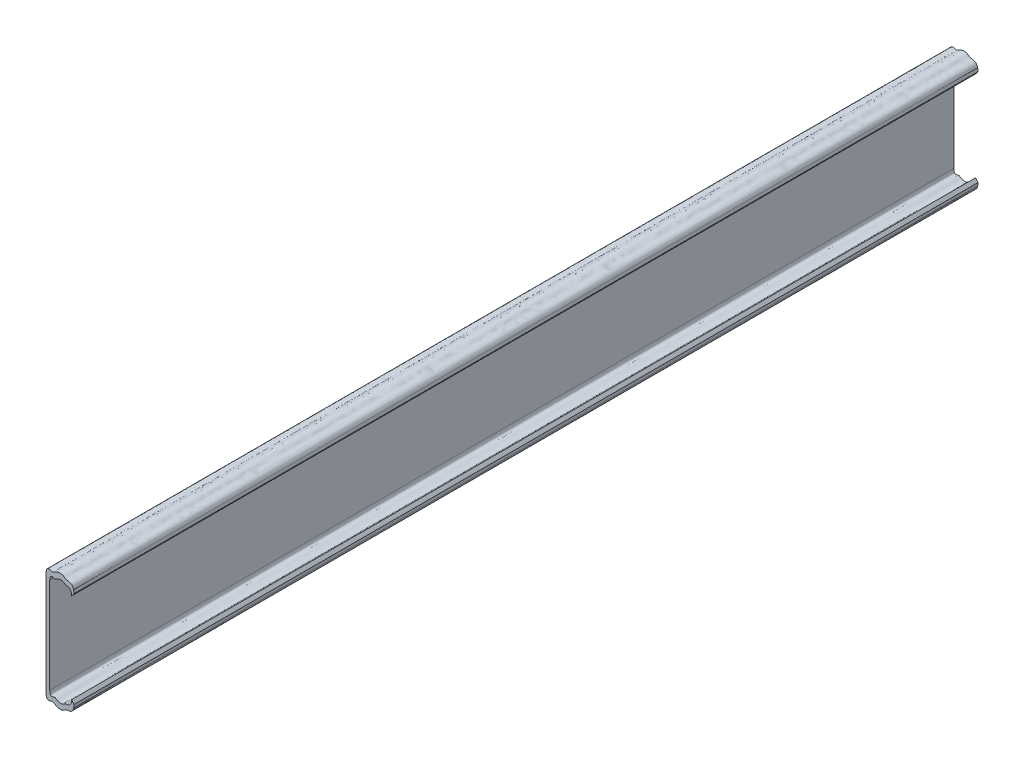
from build123d import *

# Parameters (mm, degrees)
BOSS_EXTRUDE1_DEPTH = 346


with BuildPart() as part:
    # Sketch1 → Boss-Extrude1 (new body)
    with BuildSketch(Plane.XY):
        with BuildLine():
            Line((1.430343878, 3918.17038545), (1.430343878, 3954.72901347))
            add(Edge.make_bspline(
                [(1.430343878, 3954.72901347), (1.492253744, 3955.777464486), (1.670742659, 3956.085303627), (1.952805311, 3956.243416154), (2.012188058, 3956.264605221), (2.256909987, 3956.328603169), (2.456399266, 3956.320672543), (2.757904339, 3956.259414864), (2.867475976, 3956.220539863), (3.0655829, 3956.142220977), (3.15726891, 3956.104553053), (3.353002763, 3956.075071328), (3.457565078, 3956.084802914), (3.826962952, 3956.236641407), (4.13936718, 3956.476934102), (4.679753676, 3956.732446606), (4.872375311, 3956.798700444), (5.259455237, 3956.891269903), (5.453877125, 3956.917683792), (5.821112383, 3956.92926878), (5.99223886, 3956.913589758), (6.380809615, 3956.829519875), (6.580504113, 3956.739636733), (6.800820646, 3956.589650728), (6.85125983, 3956.549497345), (7.057614936, 3956.384917414), (7.224473982, 3956.252870293), (7.694127073, 3956.129320115), (7.833489732, 3956.104363469), (7.996653054, 3956.081861553)],
                knots=[0, 0, 0, 0, 0.125, 0.125, 0.15625, 0.15625, 0.25, 0.25, 0.3125, 0.3125, 0.375, 0.375, 0.4375, 0.4375, 0.5625, 0.5625, 0.625, 0.625, 0.6875, 0.6875, 0.75, 0.75, 0.84375, 0.84375, 0.875, 0.875, 0.96875, 0.96875, 1, 1, 1, 1], degree=3))
            add(Edge.make_bspline(
                [(7.996653054, 3956.081861553), (8.088130688, 3956.069320908), (8.272759414, 3956.044010205), (8.548043297, 3955.98416982), (8.80734904, 3955.887619995), (9.114434379, 3955.705965873), (9.393499143, 3955.395178677), (9.581191859, 3954.993856883), (9.667993716, 3954.674443569), (9.713013038, 3954.432056806), (9.743778183, 3954.209962946), (9.766008001, 3953.938475631), (9.770007737, 3953.751998289), (9.772158651, 3953.651717495)],
                knots=[0, 0, 0, 0, 0.060950833, 0.123016678, 0.186644705, 0.247150337, 0.371687479, 0.497525343, 0.623449375, 0.683912366, 0.749156722, 0.865105526, 1, 1, 1, 1], degree=3))
            add(Edge.make_bspline(
                [(9.772158651, 3953.651717495), (9.902408791, 3953.815701891), (10.041613322, 3953.99095983), (10.350614598, 3954.379991179), (10.515877695, 3954.588056746), (10.692633126, 3954.810591115)],
                knots=[0, 0, 0, 0, 0.5, 0.5, 1, 1, 1, 1], degree=3))
            add(Edge.make_bspline(
                [(10.692633126, 3954.810591115), (10.691913281, 3954.862178833), (10.690503499, 3954.963210999), (10.684715317, 3955.117285928), (10.676302075, 3955.267777636), (10.659709804, 3955.478316933), (10.62998225, 3955.746722565), (10.584575759, 3955.973569096), (10.562899516, 3956.081861553)],
                knots=[0, 0, 0, 0, 0.133575651, 0.261601747, 0.383626033, 0.499198607, 0.760926415, 1, 1, 1, 1], degree=3))
            add(Edge.make_bspline(
                [(10.562899516, 3956.081861553), (10.216850212, 3957.618133962), (9.250723887, 3957.808490842), (8.406599882, 3957.92725494), (8.292912495, 3957.941948908), (7.466350409, 3958.083027006), (7.217801541, 3958.312264006), (6.889348881, 3958.571511488), (6.81435089, 3958.626610793), (6.402376678, 3958.879219503), (5.974893614, 3959.011194859), (5.200662558, 3959.003043812), (4.92380844, 3958.96768319), (4.373451983, 3958.834301949), (4.10034642, 3958.735210231), (3.596642827, 3958.481718757), (3.364114577, 3958.332529644), (2.945705944, 3958.080719754), (2.760220812, 3957.979286242), (2.283192997, 3957.874374952), (2.059716703, 3958.037572792), (1.425981171, 3958.231975183), (1.028740794, 3958.270897767), (0.359991506, 3958.004962063), (0.088038092, 3957.682417032), (0, 3956.191481358)],
                knots=[0, 0, 0, 0, 0.09375, 0.09375, 0.109375, 0.109375, 0.21875, 0.21875, 0.25, 0.25, 0.375, 0.375, 0.4375, 0.4375, 0.5, 0.5, 0.5625, 0.5625, 0.625, 0.625, 0.75, 0.75, 0.875, 0.875, 1, 1, 1, 1], degree=3))
            Line((0, 3956.191481358), (0, 3916.707917562))
            add(Edge.make_bspline(
                [(0, 3916.707917562), (0.088038092, 3915.216981887), (0.359991506, 3914.894436857), (1.028740794, 3914.628501152), (1.425981171, 3914.667423737), (2.059716703, 3914.861826128), (2.283192997, 3915.025023968), (2.760220812, 3914.920112678), (2.945705944, 3914.818679166), (3.364114577, 3914.566869275), (3.596642827, 3914.417680163), (4.10034642, 3914.164188689), (4.373451983, 3914.06509697), (4.92380844, 3913.931715729), (5.200662558, 3913.896355108), (5.974893614, 3913.888204061), (6.402376678, 3914.020179417), (6.81435089, 3914.272788127), (6.889348881, 3914.327887431), (7.217801541, 3914.587134913), (7.466350409, 3914.816371914), (8.292912495, 3914.957450011), (8.406599882, 3914.97214398), (9.250723887, 3915.090908078), (10.216850212, 3915.281264957), (10.562899516, 3916.817537367)],
                knots=[0, 0, 0, 0, 0.125, 0.125, 0.25, 0.25, 0.375, 0.375, 0.4375, 0.4375, 0.5, 0.5, 0.5625, 0.5625, 0.625, 0.625, 0.75, 0.75, 0.78125, 0.78125, 0.890625, 0.890625, 0.90625, 0.90625, 1, 1, 1, 1], degree=3))
            add(Edge.make_bspline(
                [(10.562899516, 3916.817537367), (10.574166654, 3916.870469087), (10.597285266, 3916.979077668), (10.624349071, 3917.143363024), (10.647212021, 3917.312529496), (10.669477274, 3917.52761428), (10.687102378, 3917.792322091), (10.690731297, 3917.986856854), (10.692633126, 3918.088807804)],
                knots=[0, 0, 0, 0, 0.116530115, 0.239103705, 0.367349581, 0.500883136, 0.738424956, 1, 1, 1, 1], degree=3))
            add(Edge.make_bspline(
                [(10.692633126, 3918.088807804), (10.515877695, 3918.311342173), (10.350614598, 3918.51940774), (10.041613322, 3918.90843909), (9.902408791, 3919.083697028), (9.772158651, 3919.247681425)],
                knots=[0, 0, 0, 0, 0.5, 0.5, 1, 1, 1, 1], degree=3))
            add(Edge.make_bspline(
                [(9.772158651, 3919.247681425), (9.771365289, 3919.196873909), (9.769824671, 3919.09821149), (9.762690765, 3918.943687255), (9.752032923, 3918.792605675), (9.736127422, 3918.633823813), (9.712996418, 3918.467321321), (9.66800734, 3918.224984421), (9.58118816, 3917.905535849), (9.393500286, 3917.504221803), (9.114442807, 3917.193443211), (8.807363306, 3917.011784716), (8.54805793, 3916.915232419), (8.272759456, 3916.855388689), (8.088130702, 3916.830078003), (7.996653054, 3916.817537367)],
                knots=[0, 0, 0, 0, 0.069471261, 0.134905289, 0.195584026, 0.250878315, 0.316108883, 0.376579777, 0.502497916, 0.62832989, 0.752861203, 0.813353993, 0.87698908, 0.939052019, 1, 1, 1, 1], degree=3))
            add(Edge.make_bspline(
                [(7.996653054, 3916.817537367), (7.833489732, 3916.79503545), (7.694127073, 3916.770078804), (7.224473982, 3916.646528627), (7.057614936, 3916.514481505), (6.85125983, 3916.349901574), (6.800820646, 3916.309748192), (6.580504113, 3916.159762187), (6.380809615, 3916.069879045), (5.99223886, 3915.985809162), (5.821112383, 3915.97013014), (5.453877125, 3915.981715128), (5.259455237, 3916.008129016), (4.872375311, 3916.100698475), (4.679753676, 3916.166952313), (4.13936718, 3916.422464817), (3.826962952, 3916.662757512), (3.457565078, 3916.814596005), (3.353002763, 3916.824327592), (3.15726891, 3916.794845866), (3.0655829, 3916.757177942), (2.867475976, 3916.678859056), (2.757904339, 3916.639984056), (2.456399266, 3916.578726377), (2.256909987, 3916.570795751), (2.012188058, 3916.634793698), (1.952805311, 3916.655982766), (1.670742659, 3916.814095293), (1.492253744, 3917.121934434), (1.430343878, 3918.17038545)],
                knots=[0, 0, 0, 0, 0.03125, 0.03125, 0.125, 0.125, 0.15625, 0.15625, 0.25, 0.25, 0.3125, 0.3125, 0.375, 0.375, 0.4375, 0.4375, 0.5625, 0.5625, 0.625, 0.625, 0.6875, 0.6875, 0.75, 0.75, 0.84375, 0.84375, 0.875, 0.875, 1, 1, 1, 1], degree=3))
        make_face()
    extrude(amount=BOSS_EXTRUDE1_DEPTH)


solid = part.part
